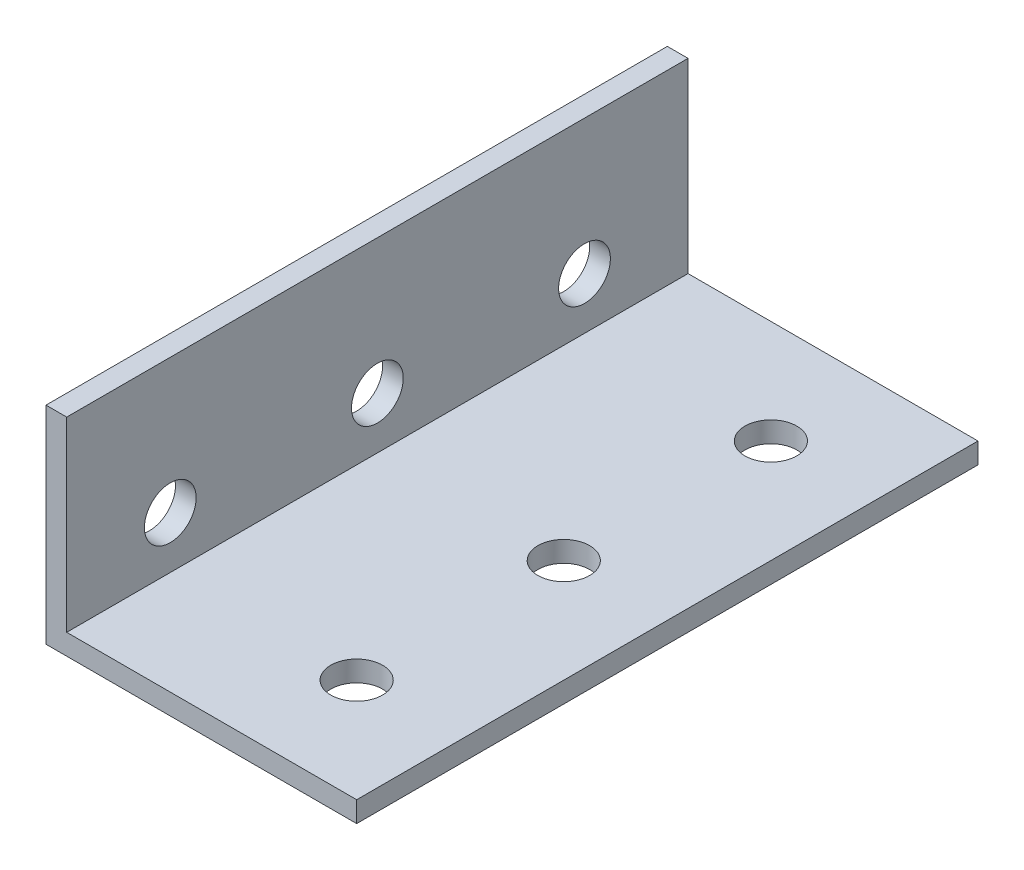
from build123d import *

# Parameters (mm, degrees)
BOSS_EXTRUDE1_DEPTH = 60
SKETCH2_R           = 2.5
CUT_EXTRUDE1_DEPTH  = 10
SKETCH3_R           = 2.5
CUT_EXTRUDE2_DEPTH  = 10


with BuildPart() as part:
    # Sketch1 → Boss-Extrude1 (new body)
    with BuildSketch(Plane.XY):
        Polygon((0, 0), (0, 20), (2, 20), (2, 2), (30, 2), (30, 0), align=None)
    extrude(amount=BOSS_EXTRUDE1_DEPTH)

    # Sketch2 → Cut-Extrude1 (cut)
    with BuildSketch(Plane(origin=(0, 2, 0), x_dir=(1, 0, 0), z_dir=(0, 1, 0))):
        with Locations((20, -30)):
            Circle(SKETCH2_R)
        with Locations((20, -10)):
            Circle(SKETCH2_R)
        with Locations((20, -50)):
            Circle(SKETCH2_R)
    extrude(amount=-CUT_EXTRUDE1_DEPTH, mode=Mode.SUBTRACT)

    # Sketch3 → Cut-Extrude2 (cut)
    with BuildSketch(Plane(origin=(2, 0, 0), x_dir=(0, 0, -1), z_dir=(1, 0, 0))):
        with Locations((-30, 7)):
            Circle(SKETCH3_R)
        with Locations((-10, 7)):
            Circle(SKETCH3_R)
        with Locations((-50, 7)):
            Circle(SKETCH3_R)
    extrude(amount=-CUT_EXTRUDE2_DEPTH, mode=Mode.SUBTRACT)


solid = part.part
